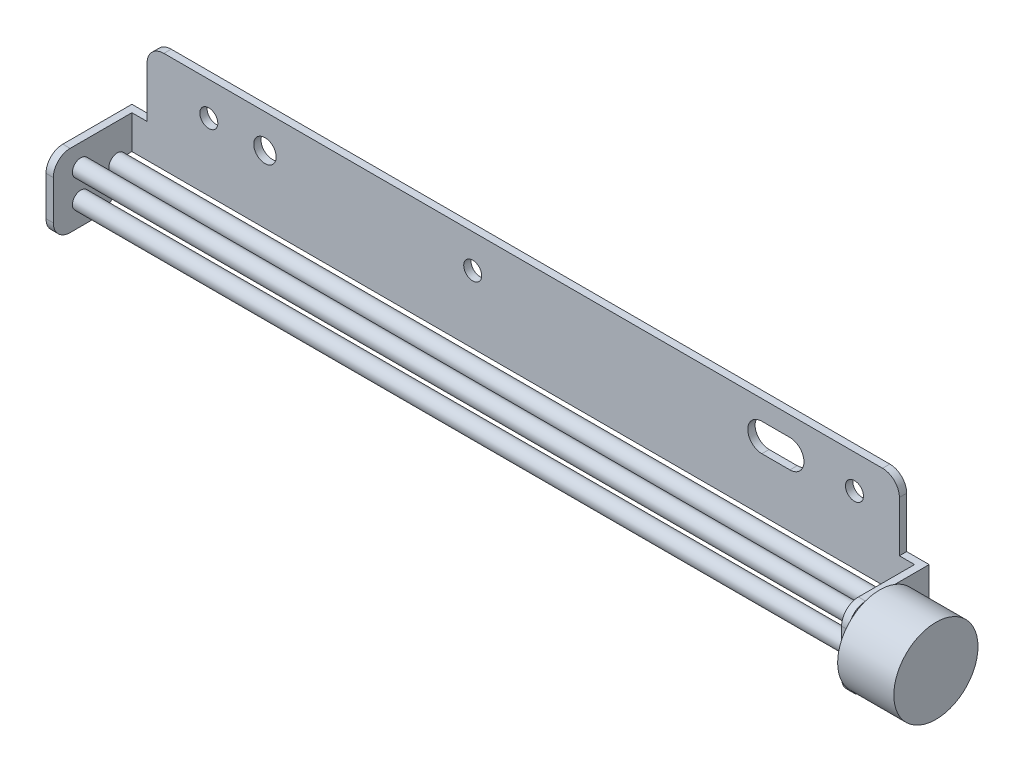
from build123d import *

# Parameters (mm, degrees)
EXTRUDE_1_DEPTH     = 1.3
FILLET_1_R          = 3
SKETCH_2_W          = 1.3
SKETCH_2_H          = 6
EXTRUDE_2_DEPTH     = 14
FILLET_2_R          = 3
SKETCH_3_W          = 1.3
SKETCH_3_H          = 7.65
EXTRUDE_3_DEPTH     = 7
SKETCH_4_W          = 1.3
SKETCH_4_H          = 4.35
EXTRUDE_4_DEPTH     = 7
FILLET_3_R          = 3
FILLET_4_R          = 5
SKETCH_6_W          = 1.3
SKETCH_6_H          = 6
EXTRUDE_5_DEPTH     = 13
SKETCH_7_W          = 1.3
SKETCH_7_H          = 13
EXTRUDE_6_DEPTH     = 8
FILLET_5_R          = 3
FILLET_6_R          = 5
SKETCH_8_R          = 1.6
SKETCH_8_R_2        = 2
CUT_EXTRUDE_1_DEPTH = 8
SKETCH_9_R          = 7.5
EXTRUDE_7_DEPTH     = 10
SKETCH_10_R         = 1.5
EXTRUDE_10_DEPTH    = 139


with BuildPart() as part:
    # 草图1 → 凸台-拉伸1 (new body)
    with BuildSketch(Plane.XY):
        Polygon((-71, 0), (0, 0), (71, 0), (71, 6), (67, 6), (67, 18), (-67, 18), (-67, 6), (-71, 6), align=None)
    extrude(amount=-EXTRUDE_1_DEPTH)

    # 圆角1
    fillet_1_edges = [part.edges().sort_by_distance(p)[0] for p in [
        (-67, 18, -0.65),
        (67, 18, -0.65),
    ]]
    fillet(fillet_1_edges, radius=FILLET_1_R)

    # 草图2 → 凸台-拉伸2 (add)
    with BuildSketch(Plane.XY):
        with Locations((-70.35, 3)):
            Rectangle(SKETCH_2_W, SKETCH_2_H)
    extrude(amount=EXTRUDE_2_DEPTH)

    # 圆角2
    fillet_2_edges = [part.edges().sort_by_distance(p)[0] for p in [
        (-70.35, 6, 14),
    ]]
    fillet(fillet_2_edges, radius=FILLET_2_R)

    # 草图3 → 凸台-拉伸3 (add)
    with BuildSketch(Plane.XZ):
        with Locations((-70.35, 10.175)):
            Rectangle(SKETCH_3_W, SKETCH_3_H)
    extrude(amount=EXTRUDE_3_DEPTH)

    # 草图4 → 凸台-拉伸4 (add)
    with BuildSketch(Plane.XZ):
        with Locations((-70.35, 4.175)):
            Rectangle(SKETCH_4_W, SKETCH_4_H)
    extrude(amount=EXTRUDE_4_DEPTH)

    # 圆角3
    fillet_3_edges = [part.edges().sort_by_distance(p)[0] for p in [
        (-70.35, -7, 14),
    ]]
    fillet(fillet_3_edges, radius=FILLET_3_R)

    # 圆角4
    fillet_4_edges = [part.edges().sort_by_distance(p)[0] for p in [
        (-70.35, -7, 2),
    ]]
    fillet(fillet_4_edges, radius=FILLET_4_R)

    # 草图6 → 凸台-拉伸5 (add)
    with BuildSketch(Plane.XY):
        with Locations((70.35, 3)):
            Rectangle(SKETCH_6_W, SKETCH_6_H)
    extrude(amount=EXTRUDE_5_DEPTH)

    # 草图7 → 凸台-拉伸6 (add)
    with BuildSketch(Plane.XZ):
        with Locations((70.35, 6.5)):
            Rectangle(SKETCH_7_W, SKETCH_7_H)
    extrude(amount=EXTRUDE_6_DEPTH)

    # 圆角5
    fillet_5_edges = [part.edges().sort_by_distance(p)[0] for p in [
        (70.35, 6, 13),
        (70.35, -8, 13),
    ]]
    fillet(fillet_5_edges, radius=FILLET_5_R)

    # 圆角6
    fillet_6_edges = [part.edges().sort_by_distance(p)[0] for p in [
        (70.35, -8, 0),
    ]]
    fillet(fillet_6_edges, radius=FILLET_6_R)

    # 草图8 → 切除-拉伸1 (cut)
    with BuildSketch(Plane.XY):
        with Locations((-56, 12)):
            Circle(SKETCH_8_R)
        with Locations((-46, 12)):
            Circle(SKETCH_8_R_2)
        with Locations((-9, 12)):
            Circle(SKETCH_8_R)
        with Locations((59, 12)):
            Circle(SKETCH_8_R)
        with BuildLine():
            Line((42.5, 14.5), (47.5, 14.5))
            ThreePointArc((47.5, 14.5), (50, 12), (47.5, 9.5))
            Line((47.5, 9.5), (42.5, 9.5))
            ThreePointArc((42.5, 9.5), (40, 12), (42.5, 14.5))
        make_face()
    extrude(amount=-CUT_EXTRUDE_1_DEPTH, mode=Mode.SUBTRACT)

    # 草图9 → 凸台-拉伸7 (add)
    with BuildSketch(Plane(origin=(71, 0, 0), x_dir=(0, 0, -1), z_dir=(1, 0, 0))):
        with Locations((-7.5, -1)):
            Circle(SKETCH_9_R)
    extrude(amount=EXTRUDE_7_DEPTH)

    # 草图10 → 凸台-拉伸10 (add)
    with BuildSketch(Plane.ZY.offset(-69.7)):
        with Locations((9.5, 2.5)):
            Circle(SKETCH_10_R)
        with Locations((9.5, -2.5)):
            Circle(SKETCH_10_R)
        with Locations((3, 0)):
            Circle(SKETCH_10_R)
    extrude(amount=EXTRUDE_10_DEPTH)


solid = part.part
